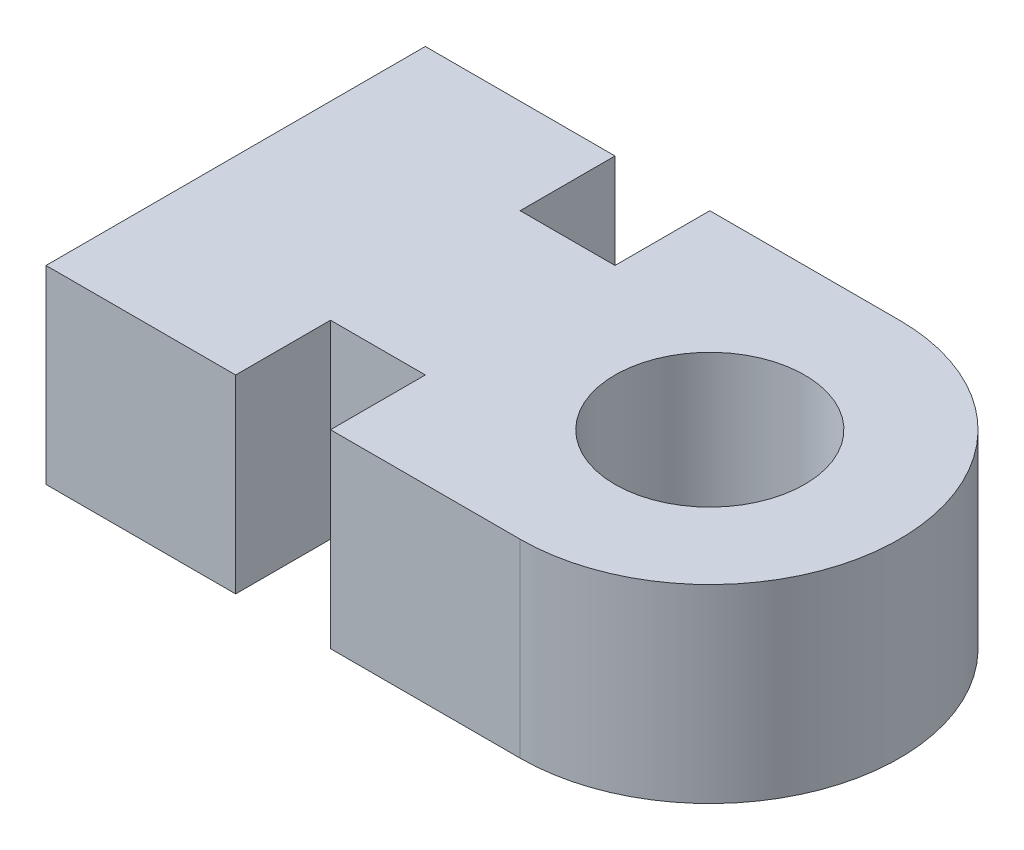
from build123d import *

# Parameters (mm, degrees)
SKETCH_1_R      = 5
EXTRUDE_1_DEPTH = 10


with BuildPart() as part:
    # 草圖1 → 填料-伸長1 (new body)
    with BuildSketch(Plane(origin=(0, 0, 0), x_dir=(1, 0, 0), z_dir=(0, 1, 0))):
        with BuildLine():
            ThreePointArc((0, -10), (10, 0), (0, 10))
            Line((0, 10), (-10, 10))
            Line((-10, 10), (-10, 5))
            Line((-10, 5), (-15, 5))
            Line((-15, 5), (-15, 10))
            Line((-15, 10), (-25, 10))
            Line((-25, 10), (-25, -10))
            Line((-25, -10), (-15, -10))
            Line((-15, -10), (-15, -5))
            Line((-15, -5), (-10, -5))
            Line((-10, -5), (-10, -10))
            Line((-10, -10), (0, -10))
        make_face()
        Circle(SKETCH_1_R, mode=Mode.SUBTRACT)
    extrude(amount=EXTRUDE_1_DEPTH)


solid = part.part
